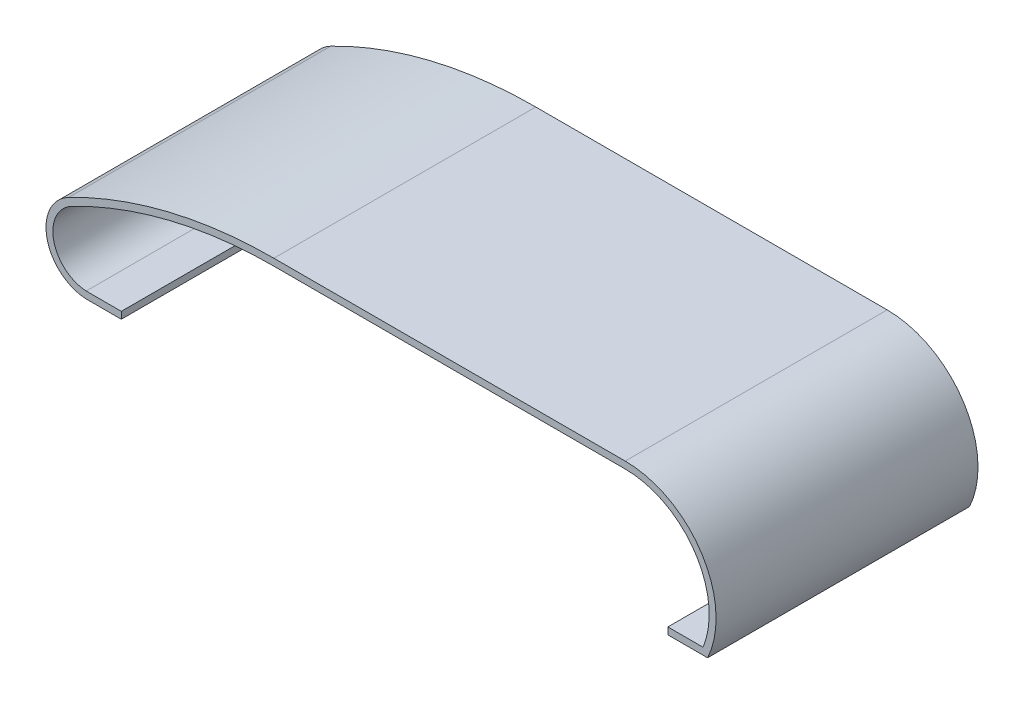
from build123d import *

# Parameters (mm, degrees)
BOSS_EXTRUDE1_DEPTH = 38


with BuildPart() as part:
    # Sketch1 → Boss-Extrude1 (new body)
    with BuildSketch(Plane.XY):
        with BuildLine():
            Line((66.52, 14.5), (15.54, 14.5))
            ThreePointArc((15.54, 14.5), (0.223169493, 12.66316181), (-14.225037528, 7.256815055))
            ThreePointArc((-14.225037528, 7.256815055), (-17.376400179, 0.546177113), (-11.711514098, -4.236375954))
            Line((-11.711514098, -4.236375954), (-6.590403043, -4.236765961))
            Line((-6.590403043, -4.236765961), (-6.590326886, -3.236765964))
            Line((-6.590326886, -3.236765964), (-11.687025279, -3.236377816))
            ThreePointArc((-11.687025279, -3.236377816), (-16.401861513, 0.77072863), (-13.765555848, 6.368627808))
            ThreePointArc((-13.765555848, 6.368627808), (0.459614785, 11.691517006), (15.54, 13.5))
            Line((15.54, 13.5), (66.52, 13.5))
            ThreePointArc((66.52, 13.5), (76.617843982, 8.130760845), (77.812974461, -3.243193847))
            Line((77.812974461, -3.243193847), (72.705055873, -3.242804844))
            Line((72.705055873, -3.242804844), (72.704979716, -4.242804841))
            Line((72.704979716, -4.242804841), (78.468410832, -4.243243765))
            ThreePointArc((78.468410832, -4.243243765), (77.633884428, 8.404811863), (66.52, 14.5))
        make_face()
    extrude(amount=BOSS_EXTRUDE1_DEPTH)


solid = part.part
